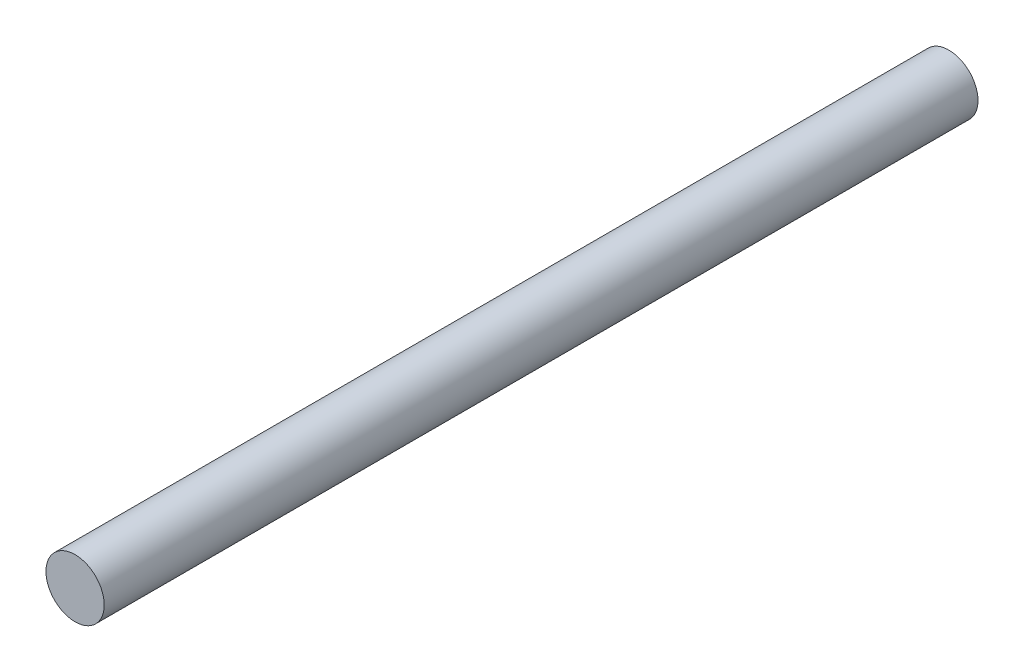
from build123d import *

# Parameters (mm, degrees)
ESQUISSE1_R        = 3
BOSS_EXTRU_1_DEPTH = 90


with BuildPart() as part:
    # Esquisse1 → Boss.-Extru.1 (new body)
    with BuildSketch(Plane.XY):
        Circle(ESQUISSE1_R)
    extrude(amount=BOSS_EXTRU_1_DEPTH)


solid = part.part
